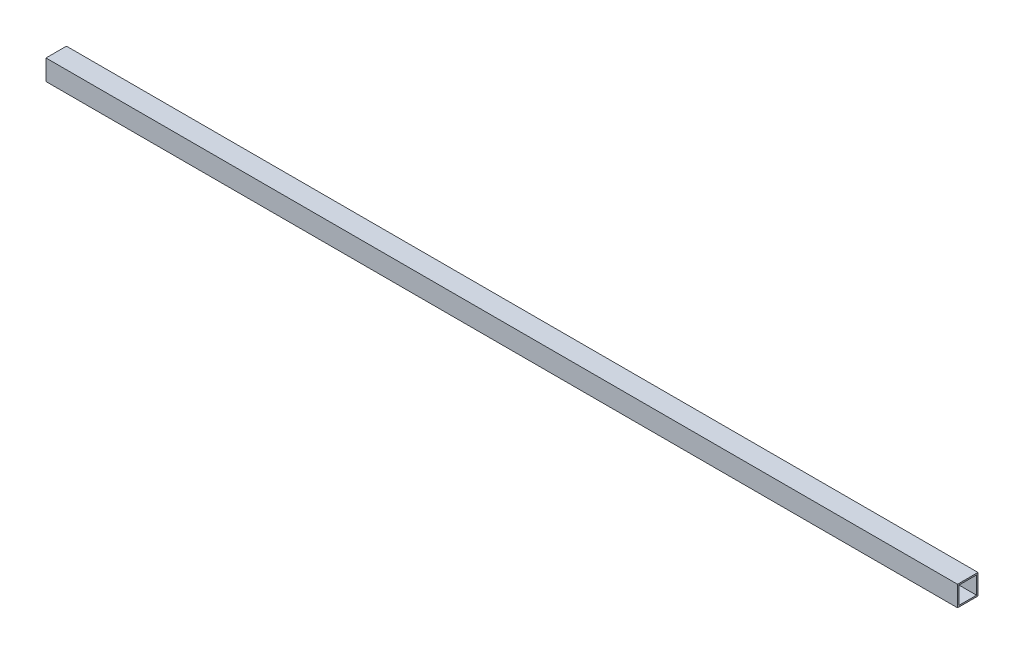
from build123d import *

# Parameters (mm, degrees)
SKETCH1_W           = 44.45
SKETCH1_H           = 44.45
SKETCH1_W_2         = 38.1
SKETCH1_H_2         = 38.1
BOSS_EXTRUDE1_DEPTH = 990.6


with BuildPart() as part:
    # Sketch1 → Boss-Extrude1 (new body, symmetric)
    with BuildSketch(Plane(origin=(0, 0, 0), x_dir=(0, 0, -1), z_dir=(1, 0, 0))):
        with Locations((22.225, 22.225)):
            Rectangle(SKETCH1_W, SKETCH1_H)
        with Locations((22.225, 22.225)):
            Rectangle(SKETCH1_W_2, SKETCH1_H_2, mode=Mode.SUBTRACT)
    extrude(amount=BOSS_EXTRUDE1_DEPTH, both=True)


solid = part.part
